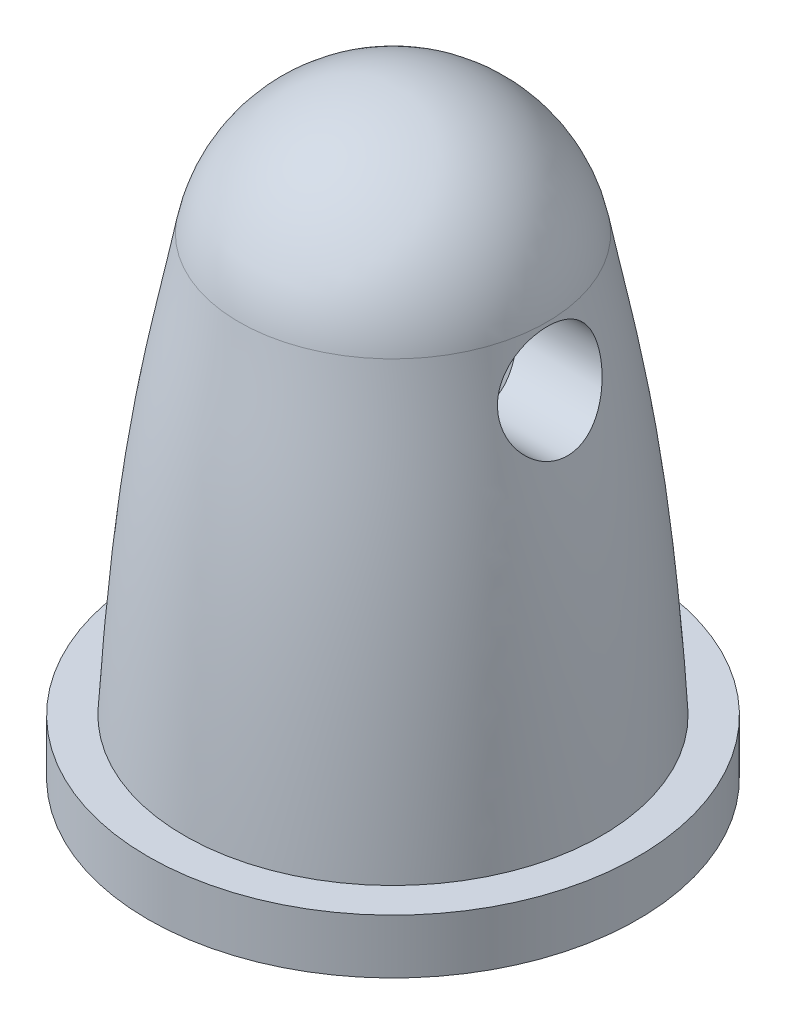
from build123d import *

# Parameters (mm, degrees)
SKETCH3_R               = 6.75
BOSS_EXTRUDE1_DEPTH     = 1.5
SKETCH5_R               = 2.5
CUT_EXTRUDE1_DEPTH      = 11
SKETCH6_R               = 1.408145202
CUT_EXTRUDE2_DEPTH      = 7.75
CUT_EXTRUDE2_DEPTH_BACK = 7.75


with BuildPart() as part:
    # Sketch1 → Revolve1 (revolve)
    with BuildSketch(Plane.XY):
        with BuildLine():
            Line((0, 0), (-5.75, 0))
            add(Edge.make_bspline(
                [(-5.75, 0), (-5.385455056, 6.49991136), (-4.801363332, 8.498230235), (-4.241672522, 11.5)],
                knots=[0, 0, 0, 0, 1, 1, 1, 1], degree=3))
            ThreePointArc((-4.241672522, 11.5), (-2.749626601, 14.012035059), (0, 15))
            Line((0, 15), (0, 0))
        make_face()
    revolve(axis=Axis((0, 15, 0), (0, -1, 0)))

    # Sketch3 → Boss-Extrude1 (add)
    with BuildSketch(Plane.XZ):
        Circle(SKETCH3_R)
    extrude(amount=BOSS_EXTRUDE1_DEPTH)

    # Sketch5 → Cut-Extrude1 (cut)
    with BuildSketch(Plane.XZ.offset(1.5)):
        Circle(SKETCH5_R)
    extrude(amount=-CUT_EXTRUDE1_DEPTH, mode=Mode.SUBTRACT)

    # Sketch6 → Cut-Extrude2 (cut, two sides)
    with BuildSketch(Plane(origin=(0, 0, 0), x_dir=(0, 0, -1), z_dir=(1, 0, 0))) as cut_extrude2_sk:
        with Locations((0, 10)):
            Circle(SKETCH6_R)
    extrude(amount=CUT_EXTRUDE2_DEPTH, mode=Mode.SUBTRACT)
    extrude(cut_extrude2_sk.sketch, amount=-CUT_EXTRUDE2_DEPTH_BACK, mode=Mode.SUBTRACT)


solid = part.part
